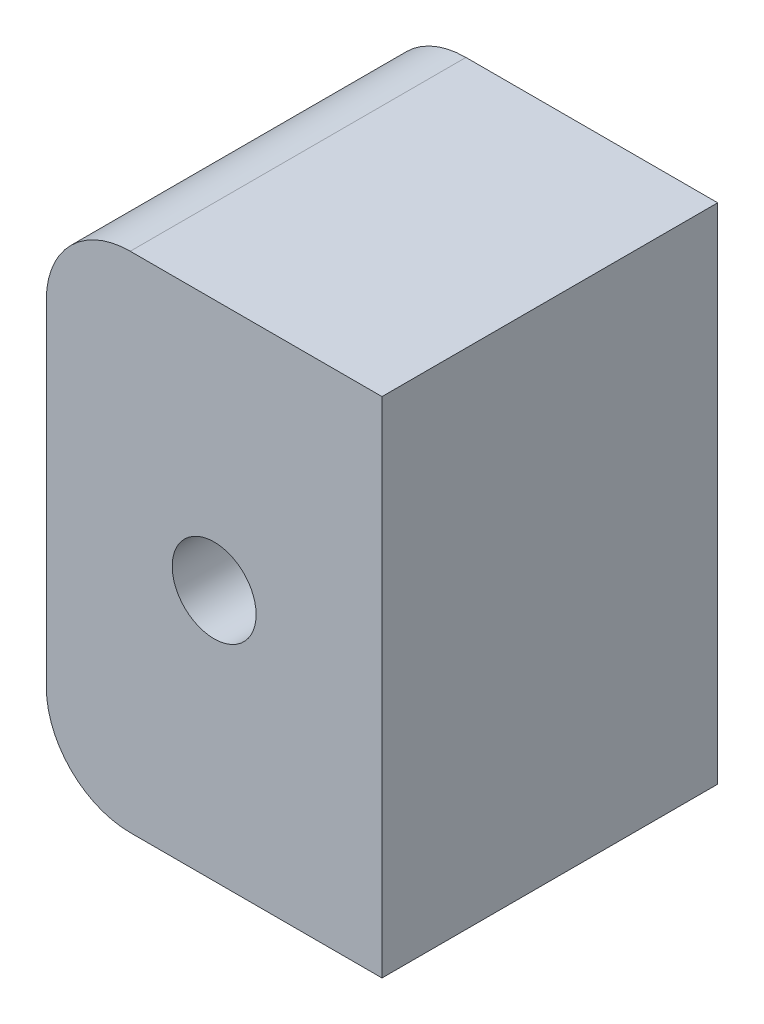
from build123d import *

# Parameters (mm, degrees)
BOSS_EXTRUDE1_DEPTH     = 20
CUT_EXTRUDE1_DEPTH      = 1
CUT_EXTRUDE1_DEPTH_BACK = 21


with BuildPart() as part:
    # Sketch1 → Boss-Extrude1 (new body)
    with BuildSketch(Plane.XY):
        with BuildLine():
            Line((-15, 15), (0, 15))
            Line((0, 15), (0, -15))
            Line((0, -15), (-15, -15))
            ThreePointArc((-15, -15), (-18.535533906, -13.535533906), (-20, -10))
            Line((-20, -10), (-20, 10))
            ThreePointArc((-20, 10), (-18.535533906, 13.535533906), (-15, 15))
        make_face()
    extrude(amount=BOSS_EXTRUDE1_DEPTH)

    # Sketch2 → Cut-Extrude1 (cut, two sides)
    with BuildSketch(Plane.XY.offset(20)) as cut_extrude1_sk:
        with BuildLine():
            ThreePointArc((-12.5, 0), (-10, -2.5), (-7.5, 0))
            Line((-7.5, 0), (-12.5, 0))
        make_face()
        with BuildLine():
            Line((-12.5, 0), (-7.5, 0))
            ThreePointArc((-7.5, 0), (-10, 2.5), (-12.5, 0))
        make_face()
    extrude(amount=CUT_EXTRUDE1_DEPTH, mode=Mode.SUBTRACT)
    extrude(cut_extrude1_sk.sketch, amount=-CUT_EXTRUDE1_DEPTH_BACK, mode=Mode.SUBTRACT)


solid = part.part
